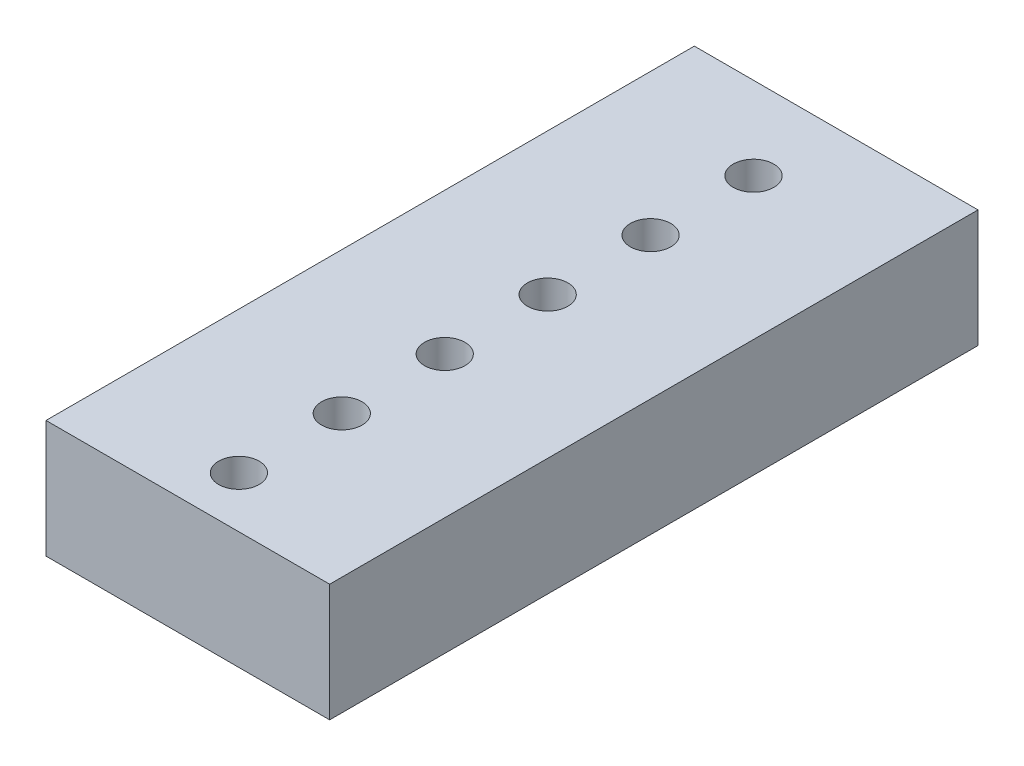
from build123d import *

# Parameters (mm, degrees)
SKETCH1_W           = 7
SKETCH1_H           = 16
BOSS_EXTRUDE1_DEPTH = 1.45
SKETCH2_R           = 0.5
CUT_EXTRUDE1_DEPTH  = 3.9
LPATTERN1_COUNT     = 12
LPATTERN1_PITCH     = 2.54


with BuildPart() as part:
    # Sketch1 → Boss-Extrude1 (new body, symmetric)
    with BuildSketch(Plane(origin=(0, 0, 0), x_dir=(1, 0, 0), z_dir=(0, 1, 0))):
        Rectangle(SKETCH1_W, SKETCH1_H)
    extrude(amount=BOSS_EXTRUDE1_DEPTH, both=True)

    # Sketch2 → Cut-Extrude1 (cut, through all)
    with BuildSketch(Plane(origin=(0, 1.45, 0), x_dir=(1, 0, 0), z_dir=(0, 1, 0))):
        with Locations((0, 5.96)):
            Circle(SKETCH2_R)
    cut_extrude1 = extrude(amount=-CUT_EXTRUDE1_DEPTH, mode=Mode.SUBTRACT)

    # LPattern1: Cut-Extrude1 ×12
    with Locations(*[(0, 0, i * LPATTERN1_PITCH) for i in range(1, LPATTERN1_COUNT)]):
        add(cut_extrude1, mode=Mode.SUBTRACT)


solid = part.part
